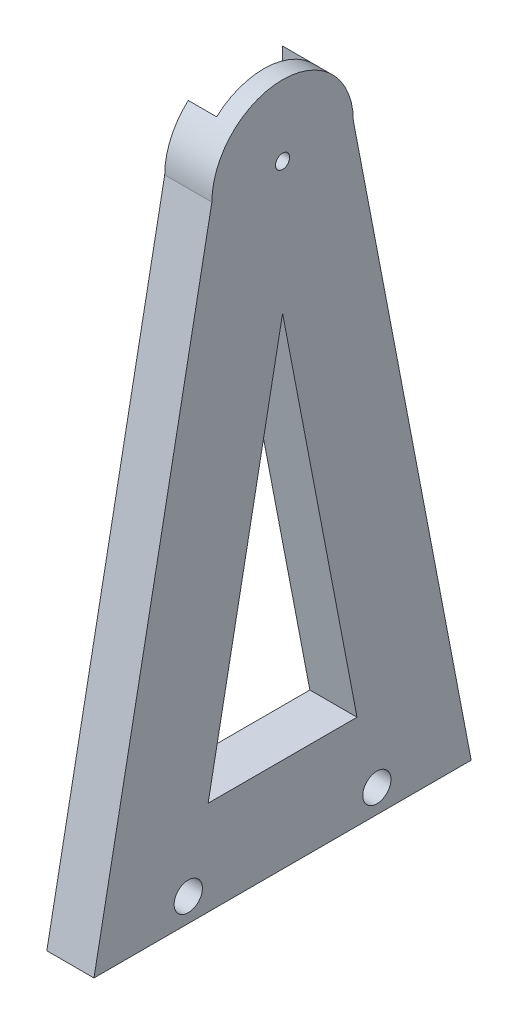
from build123d import *

# Parameters (mm, degrees)
BOSS_EXTRUDE1_DEPTH = 10
CUT_EXTRUDE1_DEPTH  = 6
SKETCH4_R           = 1.65
CUT_EXTRUDE2_DEPTH  = 11
SKETCH5_R           = 3
CUT_EXTRUDE3_DEPTH  = 5
SKETCH6_R           = 1.5
CUT_EXTRUDE4_DEPTH  = 5
CUT_EXTRUDE6_DEPTH  = 11


with BuildPart() as part:
    # Sketch2 → Boss-Extrude1 (new body)
    with BuildSketch(Plane(origin=(0, 0, 0), x_dir=(0, 0, -1), z_dir=(1, 0, 0))):
        with BuildLine():
            Line((40, 0), (-40, 0))
            Line((-40, 0), (-15, 130))
            ThreePointArc((-15, 130), (0, 145), (15, 130))
            Line((15, 130), (40, 0))
        make_face()
    extrude(amount=BOSS_EXTRUDE1_DEPTH)

    # Sketch3 → Cut-Extrude1 (cut)
    with BuildSketch(Plane.ZY):
        with BuildLine():
            Line((-10, 130), (-10, 151.126505972))
            Line((-10, 151.126505972), (10, 151.126505972))
            Line((10, 151.126505972), (10, 130))
            ThreePointArc((10, 130), (0, 120), (-10, 130))
        make_face()
    extrude(amount=-CUT_EXTRUDE1_DEPTH, mode=Mode.SUBTRACT)

    # Sketch4 → Cut-Extrude2 (cut, through all)
    with BuildSketch(Plane.ZY):
        with Locations((20, 5)):
            Circle(SKETCH4_R)
        with Locations((-20, 5)):
            Circle(SKETCH4_R)
    extrude(amount=-CUT_EXTRUDE2_DEPTH, mode=Mode.SUBTRACT)

    # Sketch5 → Cut-Extrude3 (cut)
    with BuildSketch(Plane(origin=(10, 0, 0), x_dir=(0, 0, -1), z_dir=(1, 0, 0))):
        with Locations((-20, 5)):
            Circle(SKETCH5_R)
        with Locations((20, 5)):
            Circle(SKETCH5_R)
    extrude(amount=-CUT_EXTRUDE3_DEPTH, mode=Mode.SUBTRACT)

    # Sketch6 → Cut-Extrude4 (cut, through all)
    with BuildSketch(Plane.ZY.offset(-6)):
        with Locations((0, 130)):
            Circle(SKETCH6_R)
    extrude(amount=-CUT_EXTRUDE4_DEPTH, mode=Mode.SUBTRACT)

    # Sketch7 → Cut-Extrude6 (cut, through all)
    with BuildSketch(Plane.ZY):
        Polygon((0, 102.094381641), (-15.787381085, 20), (15.787381085, 20), align=None)
    extrude(amount=-CUT_EXTRUDE6_DEPTH, mode=Mode.SUBTRACT)


solid = part.part
